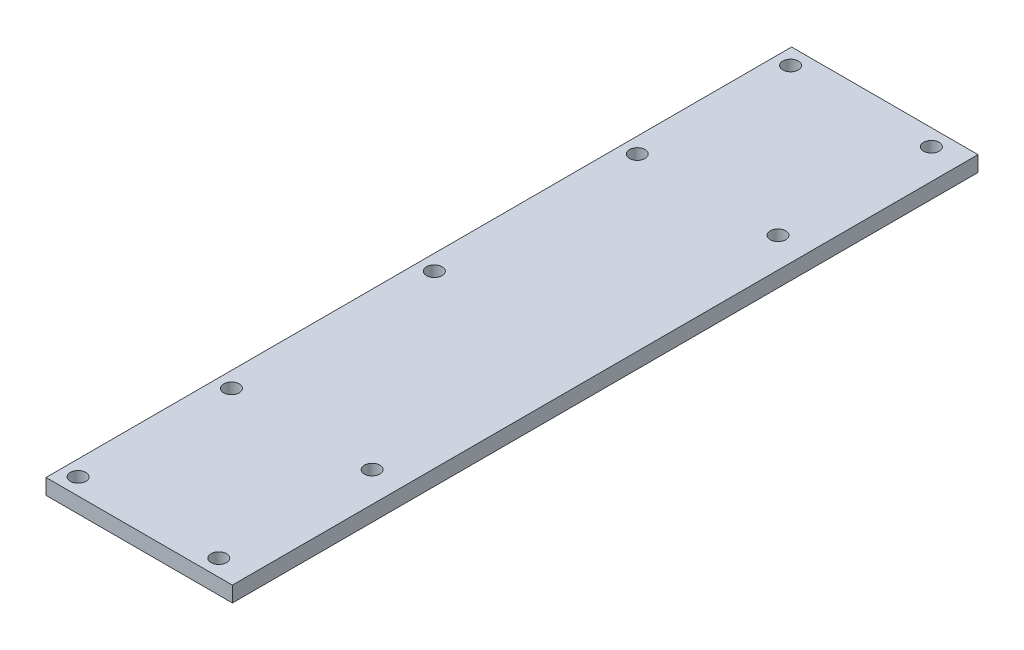
from build123d import *

# Parameters (mm, degrees)
SKETCH1_W           = 152.4
SKETCH1_H           = 609.6
BOSS_EXTRUDE1_DEPTH = 12.7
SKETCH2_R           = 6.35
CUT_EXTRUDE1_DEPTH  = 12.7


with BuildPart() as part:
    # Sketch1 → Boss-Extrude1 (new body)
    with BuildSketch(Plane(origin=(0, 0, 0), x_dir=(1, 0, 0), z_dir=(0, 1, 0))):
        with Locations((-9.172222222, -212.725)):
            Rectangle(SKETCH1_W, SKETCH1_H)
    extrude(amount=BOSS_EXTRUDE1_DEPTH)

    # Sketch2 → Cut-Extrude1 (cut)
    with BuildSketch(Plane(origin=(0, 12.7, 0), x_dir=(1, 0, 0), z_dir=(0, 1, 0))):
        with Locations((-72.672222222, -212.725)):
            Circle(SKETCH2_R)
        with Locations((-72.672222222, -378.63932586)):
            Circle(SKETCH2_R)
        with Locations((-72.672222222, -504.01067414)):
            Circle(SKETCH2_R)
        with Locations((42.386596789, -504.01067414)):
            Circle(SKETCH2_R)
        with Locations((42.386596789, -378.63932586)):
            Circle(SKETCH2_R)
        with Locations((42.386596789, -46.81067414)):
            Circle(SKETCH2_R)
        with Locations((42.386596789, 78.56067414)):
            Circle(SKETCH2_R)
        with Locations((-72.672222222, -46.81067414)):
            Circle(SKETCH2_R)
        with Locations((-72.672222222, 78.56067414)):
            Circle(SKETCH2_R)
    extrude(amount=-CUT_EXTRUDE1_DEPTH, mode=Mode.SUBTRACT)


solid = part.part
